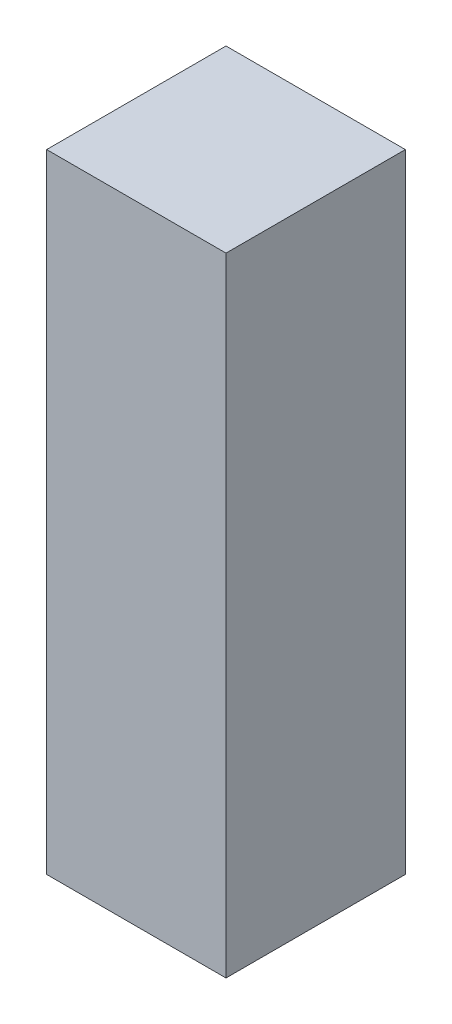
from build123d import *

# Parameters (mm, degrees)
SKETCH_1_W      = 600
SKETCH_1_H      = 600
EXTRUDE_1_DEPTH = 2100


with BuildPart() as part:
    # Эскиз1 → Бобышка-Вытянуть1 (new body)
    with BuildSketch(Plane(origin=(0, 0, 0), x_dir=(1, 0, 0), z_dir=(0, 1, 0))):
        Rectangle(SKETCH_1_W, SKETCH_1_H)
    extrude(amount=EXTRUDE_1_DEPTH)


solid = part.part
